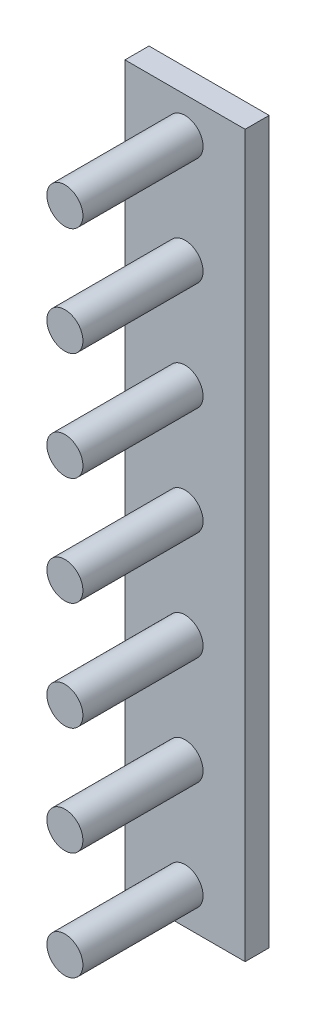
from build123d import *

# Parameters (mm, degrees)
SKETCH_1_W      = 100
SKETCH_1_H      = 600
EXTRUDE_1_DEPTH = 20
SKETCH_2_R      = 15
EXTRUDE_2_DEPTH = 100


with BuildPart() as part:
    # 草图1 → 凸台-拉伸1 (new body)
    with BuildSketch(Plane.XY):
        Rectangle(SKETCH_1_W, SKETCH_1_H)
    extrude(amount=EXTRUDE_1_DEPTH)

    # 草图2 → 凸台-拉伸2 (add)
    with BuildSketch(Plane.XY.offset(20)):
        Circle(SKETCH_2_R)
        with Locations((0, 90)):
            Circle(SKETCH_2_R)
        with Locations((0, 180)):
            Circle(SKETCH_2_R)
        with Locations((0, 270)):
            Circle(SKETCH_2_R)
        with Locations((0, -90)):
            Circle(SKETCH_2_R)
        with Locations((0, -180)):
            Circle(SKETCH_2_R)
        with Locations((0, -270)):
            Circle(SKETCH_2_R)
    extrude(amount=EXTRUDE_2_DEPTH)


solid = part.part
